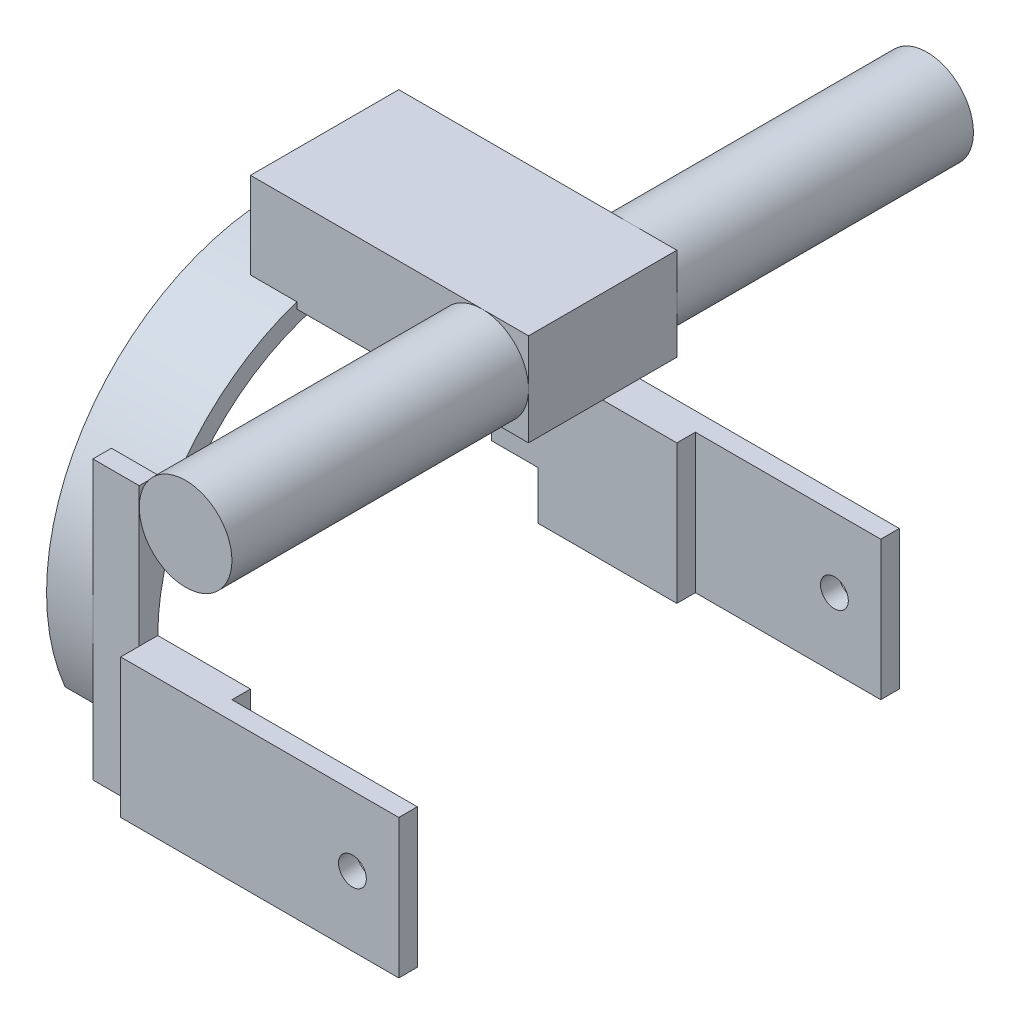
from build123d import *

# Parameters (mm, degrees)
EXTRUDE_1_DEPTH     = 20
SKETCH_2_W          = 4
SKETCH_2_H          = 30
EXTRUDE_3_DEPTH     = 20
SKETCH_4_R          = 60
SKETCH_4_R_2        = 50
CUT_EXTRUDE_2_DEPTH = 10
SKETCH_5_W          = 32
SKETCH_5_H          = 20
EXTRUDE_4_DEPTH     = 60
SKETCH_7_R          = 10
EXTRUDE_5_DEPTH     = 80
SKETCH_9_W          = 60
SKETCH_9_H          = 4
EXTRUDE_6_DEPTH     = 30
SKETCH_10_R         = 3
CUT_EXTRUDE_4_DEPTH = 135


with BuildPart() as part:
    # 草图1 → 凸台-拉伸1 (new body)
    with BuildSketch(Plane(origin=(0, 0, 0), x_dir=(0, 0, -1), z_dir=(1, 0, 0))):
        with BuildLine():
            Line((-50, 30), (-46, 30))
            Line((-46, 30), (-46, 19.595917942))
            ThreePointArc((-46, 19.595917942), (0, 50), (46, 19.595917942))
            Line((46, 19.595917942), (46, 30))
            Line((46, 30), (50, 30))
            Line((50, 30), (50, -30))
            Line((50, -30), (46, -30))
            Line((46, -30), (46, 0))
            ThreePointArc((46, 0), (0, 46), (-46, 0))
            Line((-46, 0), (-46, -30))
            Line((-46, -30), (-50, -30))
            Line((-50, -30), (-50, 30))
        make_face()
    extrude(amount=EXTRUDE_1_DEPTH)

    # 草图2 → 凸台-拉伸3 (add)
    with BuildSketch(Plane(origin=(20, 0, 0), x_dir=(0, 0, -1), z_dir=(1, 0, 0))):
        with Locations((-48, -15)):
            Rectangle(SKETCH_2_W, SKETCH_2_H)
        with Locations((48, -15)):
            Rectangle(SKETCH_2_W, SKETCH_2_H)
    extrude(amount=EXTRUDE_3_DEPTH)

    # 草图4 → 切除-拉伸2 (cut)
    with BuildSketch(Plane.ZY):
        Circle(SKETCH_4_R)
        Circle(SKETCH_4_R_2, mode=Mode.SUBTRACT)
    extrude(amount=-CUT_EXTRUDE_2_DEPTH, mode=Mode.SUBTRACT)

    # 草图5 → 凸台-拉伸4 (add)
    with BuildSketch(Plane.ZY.offset(-10)):
        with Locations((0, 56)):
            Rectangle(SKETCH_5_W, SKETCH_5_H)
    extrude(amount=-EXTRUDE_4_DEPTH)

    # 草图7 → 凸台-拉伸5 (add, symmetric)
    with BuildSketch(Plane.XY):
        with Locations((60, 56)):
            Circle(SKETCH_7_R)
    extrude(amount=EXTRUDE_5_DEPTH, both=True)

    # 草图9 → 凸台-拉伸6 (add)
    with BuildSketch(Plane.XZ.offset(30)):
        with Locations((50, -52)):
            Rectangle(SKETCH_9_W, SKETCH_9_H)
        with Locations((50, 52)):
            Rectangle(SKETCH_9_W, SKETCH_9_H)
    extrude(amount=-EXTRUDE_6_DEPTH)

    # 草图10 → 切除-拉伸4 (cut, through all)
    with BuildSketch(Plane.XY.offset(54)):
        with Locations((70, -15)):
            Circle(SKETCH_10_R)
    extrude(amount=-CUT_EXTRUDE_4_DEPTH, mode=Mode.SUBTRACT)


solid = part.part
